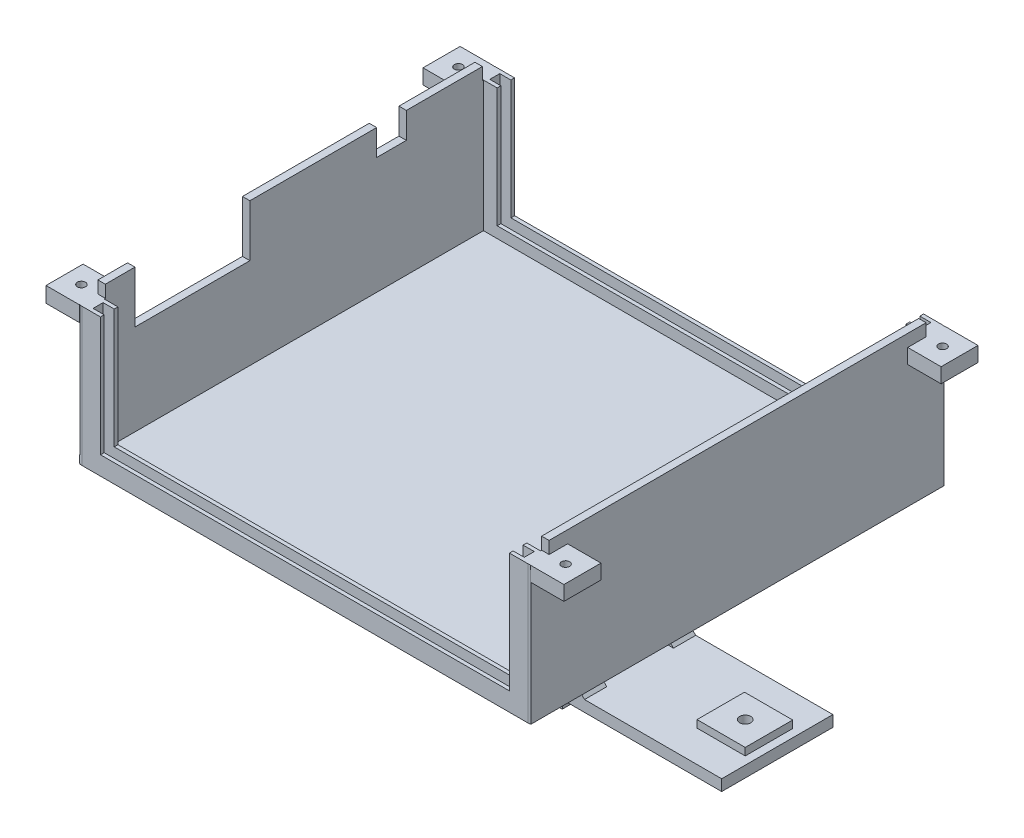
from build123d import *

# Parameters (mm, degrees)
SKETCH1_W            = 124.4
SKETCH1_H            = 111.7
BOSS_EXTRUDE1_DEPTH  = 2
SKETCH2_W            = 2
SKETCH2_H            = 101.7
BOSS_EXTRUDE2_DEPTH  = 38.5
SKETCH3_W            = 121.7
SKETCH3_H            = 4.7
BOSS_EXTRUDE3_DEPTH  = 3
SKETCH5_W            = 116.3
SKETCH5_H            = 2.7
CUT_EXTRUDE8_DEPTH   = 3
SKETCH14_W           = 121.7
SKETCH14_H           = 4.7
BOSS_EXTRUDE6_DEPTH  = 3
SKETCH15_W           = 116.3
SKETCH15_H           = 2.7
CUT_EXTRUDE14_DEPTH  = 3
SKETCH18_W           = 2
SKETCH18_H           = 0.3
BOSS_EXTRUDE7_DEPTH  = 35.2
SKETCH19_W           = 5.7
SKETCH19_H           = 4.7
BOSS_EXTRUDE8_DEPTH  = 32.2
SKETCH20_W           = 2.7
SKETCH20_H           = 32.2
CUT_EXTRUDE15_DEPTH  = 3
SKETCH21_W           = 2.7
SKETCH21_H           = 32.2
CUT_EXTRUDE16_DEPTH  = 3
SKETCH24_W           = 2.7
SKETCH24_H           = 32.2
CUT_EXTRUDE18_DEPTH  = 3
SKETCH25_W           = 2.7
SKETCH25_H           = 32.2
CUT_EXTRUDE19_DEPTH  = 3
SKETCH30_W           = 31
SKETCH30_H           = 14
SKETCH30_W_2         = 8
SKETCH30_H_2         = 7
CUT_EXTRUDE23_DEPTH  = 2
SKETCH31_W           = 6
SKETCH31_H           = 36.2
BOSS_EXTRUDE9_DEPTH  = 1.35
FILLET1_R            = 2
SKETCH33_W           = 99.7
SKETCH33_H           = 3
BOSS_EXTRUDE11_DEPTH = 1.35
SKETCH43_W           = 1.229805297
SKETCH43_H           = 112.077966817
CUT_EXTRUDE25_DEPTH  = 38.2
SKETCH47_W           = 57.12
SKETCH47_H           = 30
BOSS_EXTRUDE22_DEPTH = 38
SKETCH49_W           = 51.12
SKETCH49_H           = 30
CUT_EXTRUDE30_DEPTH  = 38
SKETCH51_W           = 2.352063359
SKETCH51_H           = 112.382279656
CUT_EXTRUDE33_DEPTH  = 77.2
SKETCH54_W           = 10
SKETCH54_H           = 4.16571725
SKETCH54_H_2         = 4.016594053
BOSS_EXTRUDE23_DEPTH = 9
SKETCH55_W           = 10
SKETCH55_H           = 3.950767522
SKETCH55_W_2         = 9.95127899
SKETCH55_H_2         = 4
BOSS_EXTRUDE24_DEPTH = 9
SKETCH56_R           = 1.1
CUT_EXTRUDE34_DEPTH  = 10
SKETCH57_R           = 1
CUT_EXTRUDE35_DEPTH  = 99.41
SKETCH58_W           = 30
SKETCH58_H           = 3
BOSS_EXTRUDE25_DEPTH = 43
SKETCH59_W           = 30
SKETCH59_H           = 3.021561104
BOSS_EXTRUDE26_DEPTH = 43
BOSS_EXTRUDE28_DEPTH = 6
BOSS_EXTRUDE29_DEPTH = 6
BOSS_EXTRUDE30_DEPTH = 6
BOSS_EXTRUDE31_DEPTH = 6
SKETCH64_W           = 30
SKETCH64_H           = 6.546083461
CUT_EXTRUDE36_DEPTH  = 101.12
SKETCH65_R           = 1.5
CUT_EXTRUDE37_DEPTH  = 6
SKETCH67_R           = 1.5
CUT_EXTRUDE39_DEPTH  = 6
SKETCH68_W           = 12.888719924
SKETCH68_H           = 13
BOSS_EXTRUDE32_DEPTH = 2
SKETCH69_W           = 13
SKETCH69_H           = 12.803280229
BOSS_EXTRUDE33_DEPTH = 2
SKETCH70_R           = 1.5
CUT_EXTRUDE40_DEPTH  = 10
SKETCH71_R           = 1.5
CUT_EXTRUDE41_DEPTH  = 10
SKETCH72_R           = 3.5
CUT_EXTRUDE42_DEPTH  = 2.2
SKETCH73_R           = 3.5
CUT_EXTRUDE43_DEPTH  = 2.2


with BuildPart() as part:
    # Sketch1 → Boss-Extrude1 (new body)
    with BuildSketch(Plane(origin=(0, 0, 0), x_dir=(1, 0, 0), z_dir=(0, 1, 0))):
        with Locations((62.2, 55.85)):
            Rectangle(SKETCH1_W, SKETCH1_H)
    extrude(amount=BOSS_EXTRUDE1_DEPTH)

    # Sketch2 → Boss-Extrude2 (add)
    with BuildSketch(Plane(origin=(0, 2, 0), x_dir=(1, 0, 0), z_dir=(0, 1, 0))):
        with Locations((122.05, 55.85)):
            Rectangle(SKETCH2_W, SKETCH2_H)
        with Locations((2.35, 55.85)):
            Rectangle(SKETCH2_W, SKETCH2_H)
    extrude(amount=BOSS_EXTRUDE2_DEPTH)

    # Sketch3 → Boss-Extrude3 (add)
    with BuildSketch(Plane(origin=(0, 2, 0), x_dir=(1, 0, 0), z_dir=(0, 1, 0))):
        with Locations((62.2, 2.35)):
            Rectangle(SKETCH3_W, SKETCH3_H)
    extrude(amount=BOSS_EXTRUDE3_DEPTH)

    # Sketch5 → Cut-Extrude8 (cut)
    with BuildSketch(Plane(origin=(0, 5, 0), x_dir=(1, 0, 0), z_dir=(0, 1, 0))):
        with Locations((62.2, 2.35)):
            Rectangle(SKETCH5_W, SKETCH5_H)
    extrude(amount=-CUT_EXTRUDE8_DEPTH, mode=Mode.SUBTRACT)

    # Sketch14 → Boss-Extrude6 (add)
    with BuildSketch(Plane(origin=(0, 2, 0), x_dir=(1, 0, 0), z_dir=(0, 1, 0))):
        with Locations((62.2, 109.35)):
            Rectangle(SKETCH14_W, SKETCH14_H)
    extrude(amount=BOSS_EXTRUDE6_DEPTH)

    # Sketch15 → Cut-Extrude14 (cut)
    with BuildSketch(Plane(origin=(0, 5, 0), x_dir=(1, 0, 0), z_dir=(0, 1, 0))):
        with Locations((62.2, 109.35)):
            Rectangle(SKETCH15_W, SKETCH15_H)
    extrude(amount=-CUT_EXTRUDE14_DEPTH, mode=Mode.SUBTRACT)

    # Sketch18 → Boss-Extrude7 (add)
    with BuildSketch(Plane(origin=(0, 2, 0), x_dir=(1, 0, 0), z_dir=(0, 1, 0))):
        with Locations((2.35, 106.85)):
            Rectangle(SKETCH18_W, SKETCH18_H)
        with Locations((122.05, 106.85)):
            Rectangle(SKETCH18_W, SKETCH18_H)
        with Locations((122.05, 4.85)):
            Rectangle(SKETCH18_W, SKETCH18_H)
        with Locations((2.35, 4.85)):
            Rectangle(SKETCH18_W, SKETCH18_H)
    extrude(amount=BOSS_EXTRUDE7_DEPTH)

    # Sketch19 → Boss-Extrude8 (add)
    with BuildSketch(Plane(origin=(0, 5, 0), x_dir=(1, 0, 0), z_dir=(0, 1, 0))):
        with Locations((120.2, 2.35)):
            Rectangle(SKETCH19_W, SKETCH19_H)
        with Locations((4.2, 2.35)):
            Rectangle(SKETCH19_W, SKETCH19_H)
        with Locations((120.2, 109.35)):
            Rectangle(SKETCH19_W, SKETCH19_H)
        with Locations((4.2, 109.35)):
            Rectangle(SKETCH19_W, SKETCH19_H)
    extrude(amount=BOSS_EXTRUDE8_DEPTH)

    # Sketch20 → Cut-Extrude15 (cut)
    with BuildSketch(Plane.ZY.offset(-117.35)):
        with Locations((-109.35, 21.1)):
            Rectangle(SKETCH20_W, SKETCH20_H)
    extrude(amount=-CUT_EXTRUDE15_DEPTH, mode=Mode.SUBTRACT)

    # Sketch21 → Cut-Extrude16 (cut)
    with BuildSketch(Plane(origin=(7.05, 0, 0), x_dir=(0, 0, -1), z_dir=(1, 0, 0))):
        with Locations((109.35, 21.1)):
            Rectangle(SKETCH21_W, SKETCH21_H)
    extrude(amount=-CUT_EXTRUDE16_DEPTH, mode=Mode.SUBTRACT)

    # Sketch24 → Cut-Extrude18 (cut)
    with BuildSketch(Plane(origin=(7.05, 0, 0), x_dir=(0, 0, -1), z_dir=(1, 0, 0))):
        with Locations((2.35, 21.1)):
            Rectangle(SKETCH24_W, SKETCH24_H)
    extrude(amount=-CUT_EXTRUDE18_DEPTH, mode=Mode.SUBTRACT)

    # Sketch25 → Cut-Extrude19 (cut)
    with BuildSketch(Plane.ZY.offset(-117.35)):
        with Locations((-2.35, 21.1)):
            Rectangle(SKETCH25_W, SKETCH25_H)
    extrude(amount=-CUT_EXTRUDE19_DEPTH, mode=Mode.SUBTRACT)

    # Sketch30 → Cut-Extrude23 (cut)
    with BuildSketch(Plane.ZY.offset(-1.35)):
        with Locations((-28.5, 33.5)):
            Rectangle(SKETCH30_W, SKETCH30_H)
        with Locations((-82.2, 37)):
            Rectangle(SKETCH30_W_2, SKETCH30_H_2)
    extrude(amount=-CUT_EXTRUDE23_DEPTH, mode=Mode.SUBTRACT)

    # Sketch31 → Boss-Extrude9 (add)
    with BuildSketch(Plane(origin=(123.05, 0, 0), x_dir=(0, 0, -1), z_dir=(1, 0, 0))):
        with Locations((3, 20.1)):
            Rectangle(SKETCH31_W, SKETCH31_H)
        with Locations((108.7, 20.1)):
            Rectangle(SKETCH31_W, SKETCH31_H)
    extrude(amount=BOSS_EXTRUDE9_DEPTH)

    # Fillet1
    fillet1_edges = [part.edges().sort_by_distance(p)[0] for p in [
        (0, 1, 0),
        (124.4, 19.1, 0),
        (124.4, 19.1, -111.7),
        (0, 1, -111.7),
    ]]
    fillet(fillet1_edges, radius=FILLET1_R)

    # Sketch33 → Boss-Extrude11 (add)
    with BuildSketch(Plane(origin=(123.05, 0, 0), x_dir=(0, 0, -1), z_dir=(1, 0, 0))):
        with Locations((55.85, 3.5)):
            Rectangle(SKETCH33_W, SKETCH33_H)
    extrude(amount=BOSS_EXTRUDE11_DEPTH)

    # Sketch43 → Cut-Extrude25 (cut, through all)
    with BuildSketch(Plane(origin=(0, 37.2, 0), x_dir=(1, 0, 0), z_dir=(0, 1, 0))):
        with Locations((0.614902649, 56.193231497)):
            Rectangle(SKETCH43_W, SKETCH43_H)
    extrude(amount=-CUT_EXTRUDE25_DEPTH, mode=Mode.SUBTRACT)

    # Sketch47 → Boss-Extrude22 (add)
    with BuildSketch(Plane(origin=(0, 0, 0), x_dir=(-1, 0, 0), z_dir=(0, -1, 0))):
        with Locations((-62.2, 55.85)):
            Rectangle(SKETCH47_W, SKETCH47_H)
    extrude(amount=BOSS_EXTRUDE22_DEPTH)

    # Sketch49 → Cut-Extrude30 (cut)
    with BuildSketch(Plane(origin=(0, -38, 0), x_dir=(-1, 0, 0), z_dir=(0, -1, 0))):
        with Locations((-62.2, 55.85)):
            Rectangle(SKETCH49_W, SKETCH49_H)
    extrude(amount=-CUT_EXTRUDE30_DEPTH, mode=Mode.SUBTRACT)

    # Sketch51 → Cut-Extrude33 (cut, through all)
    with BuildSketch(Plane(origin=(0, 38.2, 0), x_dir=(1, 0, 0), z_dir=(0, 1, 0))):
        with Locations((124.22603168, 56.299711796)):
            Rectangle(SKETCH51_W, SKETCH51_H)
    extrude(amount=-CUT_EXTRUDE33_DEPTH, mode=Mode.SUBTRACT)

    # Sketch54 → Boss-Extrude23 (add)
    with BuildSketch(Plane.ZY.offset(-1.35)):
        with Locations((-5, 35.117141375)):
            Rectangle(SKETCH54_W, SKETCH54_H)
        with Locations((-106.7, 35.191702973)):
            Rectangle(SKETCH54_W, SKETCH54_H_2)
    extrude(amount=BOSS_EXTRUDE23_DEPTH)

    # Sketch55 → Boss-Extrude24 (add)
    with BuildSketch(Plane(origin=(123.05, 0, 0), x_dir=(0, 0, -1), z_dir=(1, 0, 0))):
        with Locations((5, 35.224616239)):
            Rectangle(SKETCH55_W, SKETCH55_H)
        with Locations((106.724360505, 35.2)):
            Rectangle(SKETCH55_W_2, SKETCH55_H_2)
    extrude(amount=BOSS_EXTRUDE24_DEPTH)

    # Sketch56 → Cut-Extrude34 (cut)
    with BuildSketch(Plane(origin=(0, 37.2, 0), x_dir=(1, 0, 0), z_dir=(0, 1, 0))):
        with Locations((-3.1, 106.7)):
            Circle(SKETCH56_R)
        with Locations((127.5, 106.7)):
            Circle(SKETCH56_R)
        with Locations((127.5, 5)):
            Circle(SKETCH56_R)
        with Locations((-3.1, 5)):
            Circle(SKETCH56_R)
    extrude(amount=-CUT_EXTRUDE34_DEPTH, mode=Mode.SUBTRACT)

    # Sketch57 → Cut-Extrude35 (cut, through all)
    with BuildSketch(Plane(origin=(90.76, 0, 0), x_dir=(0, 0, -1), z_dir=(1, 0, 0))):
        with Locations((45.85, -34)):
            Circle(SKETCH57_R)
        with Locations((65.85, -34)):
            Circle(SKETCH57_R)
    extrude(amount=-CUT_EXTRUDE35_DEPTH, mode=Mode.SUBTRACT)

    # Sketch58 → Boss-Extrude25 (add)
    with BuildSketch(Plane(origin=(90.76, 0, 0), x_dir=(0, 0, -1), z_dir=(1, 0, 0))):
        with Locations((55.85, -29.25)):
            Rectangle(SKETCH58_W, SKETCH58_H)
    extrude(amount=BOSS_EXTRUDE25_DEPTH)

    # Sketch59 → Boss-Extrude26 (add)
    with BuildSketch(Plane.ZY.offset(-33.64)):
        with Locations((-55.85, -29.239219448)):
            Rectangle(SKETCH59_W, SKETCH59_H)
    extrude(amount=BOSS_EXTRUDE26_DEPTH)

    # Sketch61 → Boss-Extrude28 (add)
    with BuildSketch(Plane.XY.offset(-40.85)):
        Polygon((90.76, -21.75), (96.76, -27.75), (90.76, -27.75), align=None)
    extrude(amount=-BOSS_EXTRUDE28_DEPTH)

    # Sketch62 → Boss-Extrude29 (add)
    with BuildSketch(Plane(origin=(0, 0, -70.85), x_dir=(-1, 0, 0), z_dir=(0, 0, -1))):
        Polygon((-90.76, -21.75), (-90.76, -27.75), (-96.76, -27.75), align=None)
    extrude(amount=-BOSS_EXTRUDE29_DEPTH)

    # Sketch60 → Boss-Extrude30 (add)
    with BuildSketch(Plane.XY.offset(-40.85)):
        Polygon((27.64, -27.728438896), (33.64, -21.728438896), (33.64, -27.728438896), align=None)
    extrude(amount=-BOSS_EXTRUDE30_DEPTH)

    # Sketch63 → Boss-Extrude31 (add)
    with BuildSketch(Plane(origin=(0, 0, -70.85), x_dir=(-1, 0, 0), z_dir=(0, 0, -1))):
        Polygon((-33.64, -22.069435851), (-33.64, -27.728438896), (-27.64, -27.728438896), align=None)
    extrude(amount=-BOSS_EXTRUDE31_DEPTH)

    # Sketch64 → Cut-Extrude36 (cut, through all)
    with BuildSketch(Plane.ZY.offset(-33.64)):
        with Locations((-55.85, -36.27304173)):
            Rectangle(SKETCH64_W, SKETCH64_H)
    extrude(amount=-CUT_EXTRUDE36_DEPTH, mode=Mode.SUBTRACT)

    # Sketch65 → Cut-Extrude37 (cut)
    with BuildSketch(Plane(origin=(0, -30.75, 0), x_dir=(-1, 0, 0), z_dir=(0, -1, 0))):
        with Locations((-125.11, 55.85)):
            Circle(SKETCH65_R)
    extrude(amount=-CUT_EXTRUDE37_DEPTH, mode=Mode.SUBTRACT)

    # Sketch67 → Cut-Extrude39 (cut)
    with BuildSketch(Plane.XZ.offset(30.75)):
        with Locations((-0.71, -55.85)):
            Circle(SKETCH67_R)
    extrude(amount=-CUT_EXTRUDE39_DEPTH, mode=Mode.SUBTRACT)

    # Sketch68 → Boss-Extrude32 (add)
    with BuildSketch(Plane(origin=(0, -27.728438896, 0), x_dir=(1, 0, 0), z_dir=(0, 1, 0))):
        with Locations((-0.765640038, 55.85)):
            Rectangle(SKETCH68_W, SKETCH68_H)
    extrude(amount=BOSS_EXTRUDE32_DEPTH)

    # Sketch69 → Boss-Extrude33 (add)
    with BuildSketch(Plane(origin=(0, -27.75, 0), x_dir=(1, 0, 0), z_dir=(0, 1, 0))):
        with Locations((125.11, 55.751640115)):
            Rectangle(SKETCH69_W, SKETCH69_H)
    extrude(amount=BOSS_EXTRUDE33_DEPTH)

    # Sketch70 → Cut-Extrude40 (cut)
    with BuildSketch(Plane(origin=(0, -30.75, 0), x_dir=(-1, 0, 0), z_dir=(0, -1, 0))):
        with Locations((-125.11, 55.85)):
            Circle(SKETCH70_R)
    extrude(amount=-CUT_EXTRUDE40_DEPTH, mode=Mode.SUBTRACT)

    # Sketch71 → Cut-Extrude41 (cut)
    with BuildSketch(Plane(origin=(0, -30.75, 0), x_dir=(-1, 0, 0), z_dir=(0, -1, 0))):
        with Locations((0.71, 55.85)):
            Circle(SKETCH71_R)
    extrude(amount=-CUT_EXTRUDE41_DEPTH, mode=Mode.SUBTRACT)

    # Sketch72 → Cut-Extrude42 (cut)
    with BuildSketch(Plane(origin=(0, -30.75, 0), x_dir=(-1, 0, 0), z_dir=(0, -1, 0))):
        with Locations((0.71, 55.85)):
            Circle(SKETCH72_R)
    extrude(amount=-CUT_EXTRUDE42_DEPTH, mode=Mode.SUBTRACT)

    # Sketch73 → Cut-Extrude43 (cut)
    with BuildSketch(Plane(origin=(0, -30.75, 0), x_dir=(-1, 0, 0), z_dir=(0, -1, 0))):
        with Locations((-125.11, 55.85)):
            Circle(SKETCH73_R)
    extrude(amount=-CUT_EXTRUDE43_DEPTH, mode=Mode.SUBTRACT)


solid = part.part
